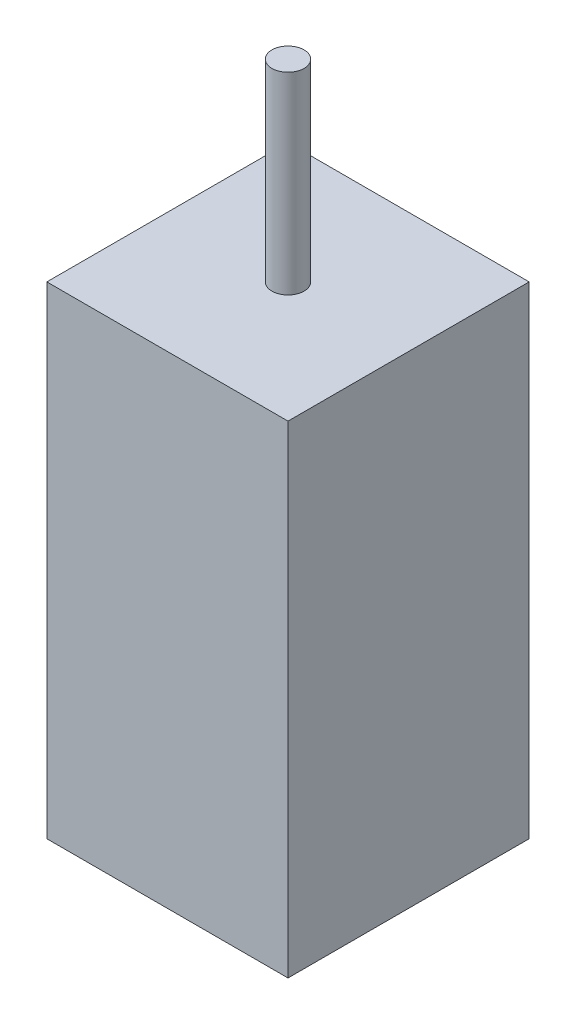
from build123d import *

# Parameters (mm, degrees)
SKETCH3_W           = 15
SKETCH3_H           = 15
BOSS_EXTRUDE1_DEPTH = 30
SKETCH4_R           = 1
BOSS_EXTRUDE2_DEPTH = 12


with BuildPart() as part:
    # Sketch3 → Boss-Extrude1 (new body)
    with BuildSketch(Plane(origin=(0, 0, 0), x_dir=(1, 0, 0), z_dir=(0, 1, 0))):
        Rectangle(SKETCH3_W, SKETCH3_H)
    extrude(amount=BOSS_EXTRUDE1_DEPTH)

    # Sketch4 → Boss-Extrude2 (add)
    with BuildSketch(Plane(origin=(0, 30, 0), x_dir=(1, 0, 0), z_dir=(0, 1, 0))):
        Circle(SKETCH4_R)
    extrude(amount=BOSS_EXTRUDE2_DEPTH)


solid = part.part
